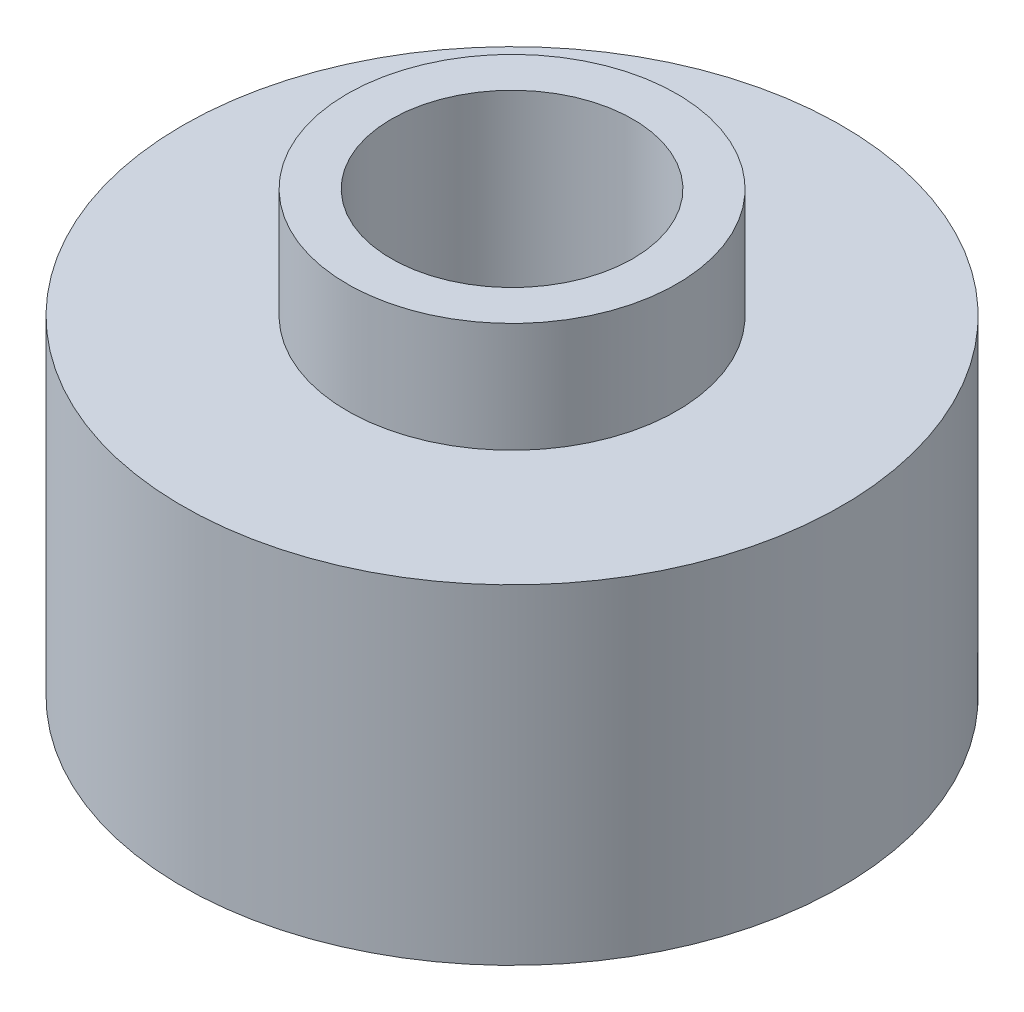
from build123d import *

# Parameters (mm, degrees)
SKETCH2_R          = 3.4925
CUT_EXTRUDE1_DEPTH = 13.7


with BuildPart() as part:
    # Sketch1 → Revolve1 (revolve)
    with BuildSketch(Plane.XY):
        Polygon((0, 0), (9.525, 0), (9.525, 9.525), (4.7625, 9.525), (4.7625, 12.7), (0, 12.7), align=None)
    revolve(axis=Axis((0, 12.7, 0), (0, -1, 0)))

    # Sketch2 → Cut-Extrude1 (cut, through all)
    with BuildSketch(Plane(origin=(0, 12.7, 0), x_dir=(1, 0, 0), z_dir=(0, 1, 0))):
        Circle(SKETCH2_R)
    extrude(amount=-CUT_EXTRUDE1_DEPTH, mode=Mode.SUBTRACT)


solid = part.part
